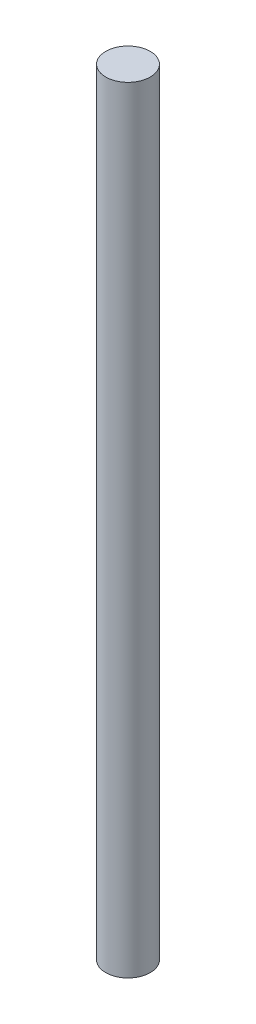
from build123d import *

# Parameters (mm, degrees)
SKETCH1_R           = 1.55
BOSS_EXTRUDE1_DEPTH = 54


with BuildPart() as part:
    # Sketch1 → Boss-Extrude1 (new body)
    with BuildSketch(Plane(origin=(0, 0, 0), x_dir=(1, 0, 0), z_dir=(0, 1, 0))):
        Circle(SKETCH1_R)
    extrude(amount=BOSS_EXTRUDE1_DEPTH)


solid = part.part
